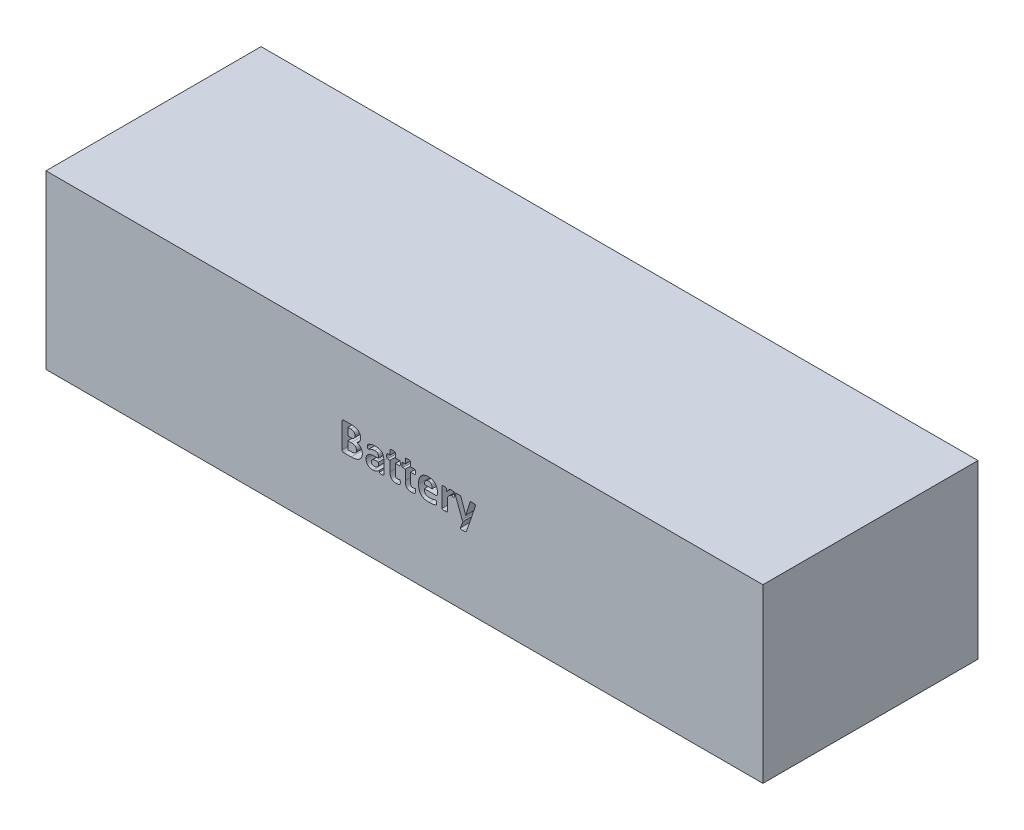
from build123d import *

# Parameters (mm, degrees)
SKETCH1_W           = 500
SKETCH1_H           = 120
BOSS_EXTRUDE1_DEPTH = 150
CUT_EXTRUDE1_DEPTH  = 10


with BuildPart() as part:
    # Sketch1 → Boss-Extrude1 (new body)
    with BuildSketch(Plane.XY):
        Rectangle(SKETCH1_W, SKETCH1_H)
    extrude(amount=BOSS_EXTRUDE1_DEPTH)

    # Sketch2 → Cut-Extrude1 (cut)
    with BuildSketch(Plane.XY.offset(150)):
        with BuildLine():
            add(Edge.make_bspline(
                [(-29.389203198, -0.522577242), (-29.392504078, -0.69222212), (-29.398977209, -1.024901137), (-29.454384378, -1.512436541), (-29.542909639, -1.976332964), (-29.668986073, -2.41438336), (-29.829526734, -2.824338476), (-30.007530188, -3.215106909), (-30.219628532, -3.578967128), (-30.45954757, -3.918915264), (-30.726422991, -4.233111364), (-31.013436073, -4.528778521), (-31.332578049, -4.792760853), (-31.78396216, -5.126625411), (-32.409994719, -5.482220629), (-33.220744095, -5.8292766), (-34.097537507, -6.088226347), (-34.867437693, -6.240005424), (-35.516882295, -6.322710703), (-36.03629251, -6.367237394), (-36.582653361, -6.394401234), (-36.956401093, -6.397690597), (-37.14692621, -6.399367413)],
                knots=[0, 0, 0, 0, 0.924869681, 1.813698953, 2.671929785, 3.497741784, 4.295238828, 5.071047982, 5.837050105, 6.588235223, 7.337056364, 8.083192266, 8.832013407, 9.592756872, 11.143016317, 12.74439455, 14.392794953, 16.118857481, 17.017754023, 17.961953565, 18.961066516, 20, 20, 20, 20], degree=3))
            Line((-37.14692621, -6.399367413), (-42.326241283, -6.399367413))
            add(Edge.make_bspline(
                [(-42.326241283, -6.399367413), (-42.406047684, -6.396172219), (-42.560144742, -6.390002664), (-42.783672631, -6.33429987), (-42.984788028, -6.238257068), (-43.171002952, -6.11287696), (-43.325125901, -5.93741184), (-43.425182233, -5.709751978), (-43.489795596, -5.441447853), (-43.496890124, -5.247856286), (-43.50069935, -5.143912238)],
                knots=[0, 0, 0, 0, 0.978793994, 1.889939582, 2.804428835, 3.703585142, 4.63041425, 5.627232269, 6.726002966, 8, 8, 8, 8], degree=3))
            Line((-43.50069935, -5.143912238), (-43.50069935, 11.928478195))
            add(Edge.make_bspline(
                [(-43.50069935, 11.928478195), (-43.496811216, 12.032392918), (-43.489569724, 12.225929869), (-43.426228101, 12.493263141), (-43.32397279, 12.718626901), (-43.169706837, 12.892493891), (-42.986302589, 13.023492234), (-42.783479905, 13.118588137), (-42.560197039, 13.174643972), (-42.406065527, 13.180763884), (-42.326241283, 13.183933369)],
                knots=[0, 0, 0, 0, 1.274945825, 2.374534816, 3.355443708, 4.282963059, 5.193482606, 6.108652912, 7.020477063, 8, 8, 8, 8], degree=3))
            Line((-42.326241283, 13.183933369), (-37.425916249, 13.183933369))
            add(Edge.make_bspline(
                [(-37.425916249, 13.183933369), (-37.139318902, 13.18112109), (-36.586474342, 13.175696221), (-35.793268987, 13.116732227), (-35.067486787, 13.023092055), (-34.406097693, 12.895564456), (-33.803680828, 12.722043568), (-33.249439583, 12.518450127), (-32.748952555, 12.264274438), (-32.295844863, 11.975969666), (-31.889192629, 11.65043714), (-31.537767337, 11.280191934), (-31.236717403, 10.868216764), (-30.983314365, 10.417534962), (-30.786292431, 9.923861306), (-30.640030909, 9.390107338), (-30.554988811, 8.81433785), (-30.545848203, 8.415886058), (-30.541162068, 8.211610905)],
                knots=[0, 0, 0, 0, 1.422535359, 2.744062161, 3.945671556, 5.054054835, 6.084028266, 7.054893494, 7.980650676, 8.864712083, 9.717130842, 10.559835018, 11.390878574, 12.24430494, 13.119573574, 14.022776017, 14.986332244, 16, 16, 16, 16], degree=3))
            add(Edge.make_bspline(
                [(-30.541162068, 8.211610905), (-30.549470182, 7.981431788), (-30.565801637, 7.52896333), (-30.703858776, 6.875425266), (-30.924208584, 6.269213116), (-31.231935264, 5.7198456), (-31.625496819, 5.231303791), (-32.097301907, 4.808347194), (-32.640393257, 4.444409803), (-33.047160307, 4.275088914), (-33.254565186, 4.18875454)],
                knots=[0, 0, 0, 0, 1.064274459, 2.092069132, 3.075913786, 4.039345789, 4.992217936, 5.965278652, 6.962523792, 8, 8, 8, 8], degree=3))
            add(Edge.make_bspline(
                [(-33.254565186, 4.18875454), (-33.119121116, 4.160665196), (-32.850280107, 4.104911055), (-32.458115034, 3.988357529), (-32.084227882, 3.838625604), (-31.727223164, 3.663195415), (-31.389176093, 3.459285828), (-31.067457985, 3.232366103), (-30.776521906, 2.96813342), (-30.504292974, 2.68369598), (-30.255058051, 2.374342169), (-30.040297334, 2.032121108), (-29.844362606, 1.668742066), (-29.684190854, 1.276007438), (-29.552100894, 0.861189762), (-29.458617994, 0.421193283), (-29.397791611, -0.042387568), (-29.39210409, -0.360384494), (-29.389203198, -0.522577242)],
                knots=[0, 0, 0, 0, 0.996598969, 1.978135123, 2.943647814, 3.896000454, 4.841457252, 5.786419563, 6.728099347, 7.668537465, 8.622361299, 9.584904388, 10.576213204, 11.593984834, 12.63670833, 13.709533826, 14.831759139, 16, 16, 16, 16], degree=3))
        make_face()
        with BuildLine():
            add(Edge.make_bspline(
                [(-34.573018111, 7.775126489), (-34.581179947, 7.964982884), (-34.596875041, 8.330074043), (-34.729526291, 8.845202786), (-34.941811852, 9.296146249), (-35.257488186, 9.664917646), (-35.659013468, 9.955212287), (-36.064378704, 10.116546405), (-36.435339134, 10.21869895), (-36.76747533, 10.268862997), (-37.143280217, 10.300801742), (-37.407836416, 10.302919108), (-37.547411911, 10.304036195)],
                knots=[0, 0, 0, 0, 1.269297621, 2.440841347, 3.536685647, 4.57691547, 5.655600639, 6.821276254, 7.476564334, 8.229395514, 9.06585823, 10, 10, 10, 10], degree=3))
            Line((-37.547411911, 10.304036195), (-39.468843306, 10.304036195))
            Line((-39.468843306, 10.304036195), (-39.468843306, 5.120221282))
            Line((-39.468843306, 5.120221282), (-37.344919141, 5.120221282))
            add(Edge.make_bspline(
                [(-37.344919141, 5.120221282), (-37.214280366, 5.122402547), (-36.96581011, 5.126551233), (-36.61536102, 5.168152582), (-36.305069192, 5.227860039), (-35.955043078, 5.346946433), (-35.577163407, 5.554458468), (-35.203042448, 5.886141458), (-34.915476582, 6.288602931), (-34.720869548, 6.750801071), (-34.595251161, 7.251042352), (-34.580495162, 7.598875197), (-34.573018111, 7.775126489)],
                knots=[0, 0, 0, 0, 0.897651758, 1.707301395, 2.423204266, 3.065599642, 4.242445143, 5.359969752, 6.47597094, 7.611991682, 8.789966051, 10, 10, 10, 10], degree=3))
        make_face(mode=Mode.SUBTRACT)
        with BuildLine():
            add(Edge.make_bspline(
                [(-33.421059242, -0.585574993), (-33.423520691, -0.47595297), (-33.428293041, -0.263413656), (-33.469171059, 0.047471883), (-33.540211263, 0.338779236), (-33.641442708, 0.61045153), (-33.761632842, 0.86655433), (-33.914483296, 1.098549624), (-34.093379626, 1.309500689), (-34.297744797, 1.499065016), (-34.528437383, 1.67222786), (-34.791894443, 1.820935363), (-35.086046489, 1.944535604), (-35.409810461, 2.05544354), (-35.774183292, 2.14129615), (-36.187044737, 2.196720279), (-36.649813125, 2.232632812), (-36.975856904, 2.237677337), (-37.14692621, 2.240324109)],
                knots=[0, 0, 0, 0, 0.985477707, 1.910681348, 2.813592447, 3.675578793, 4.514135175, 5.352148978, 6.165595806, 6.995866717, 7.853727436, 8.753813147, 9.708438657, 10.71934223, 11.82842252, 13.068320276, 14.461800387, 16, 16, 16, 16], degree=3))
            Line((-37.14692621, 2.240324109), (-39.468843306, 2.240324109))
            Line((-39.468843306, 2.240324109), (-39.468843306, -3.231480521))
            Line((-39.468843306, -3.231480521), (-36.638444365, -3.231480521))
            add(Edge.make_bspline(
                [(-36.638444365, -3.231480521), (-36.50780833, -3.230892295), (-36.254986153, -3.22975389), (-35.89509041, -3.189305571), (-35.564112034, -3.144832414), (-35.177460383, -3.042713013), (-34.740365421, -2.869917994), (-34.283288866, -2.573889565), (-33.911939435, -2.189303071), (-33.683360751, -1.804488761), (-33.543508017, -1.466116428), (-33.475411932, -1.186735923), (-33.426820652, -0.891755453), (-33.423010798, -0.689287196), (-33.421059242, -0.585574993)],
                knots=[0, 0, 0, 0, 0.996438702, 1.928425049, 2.762412092, 3.542798089, 4.97591562, 6.331990048, 7.668146545, 9.019184108, 9.722981391, 10.456157892, 11.209183361, 12, 12, 12, 12], degree=3))
        make_face(mode=Mode.SUBTRACT)
        with BuildLine():
            add(Edge.make_bspline(
                [(-14.413737895, -5.836887496), (-14.418770545, -5.903865725), (-14.428547402, -6.03398338), (-14.56760196, -6.194017502), (-14.781802833, -6.288821213), (-15.006436653, -6.344232638), (-15.236856633, -6.370041042), (-15.457340555, -6.389052052), (-15.718661831, -6.395735991), (-15.906188983, -6.398100383), (-16.006681019, -6.399367413)],
                knots=[0, 0, 0, 0, 0.847661055, 1.646739115, 2.582838834, 3.842570661, 4.623823176, 5.576626076, 6.701362571, 8, 8, 8, 8], degree=3))
            add(Edge.make_bspline(
                [(-16.006681019, -6.399367413), (-16.113187169, -6.398340274), (-16.309739574, -6.396444735), (-16.581283194, -6.387147356), (-16.806671031, -6.375890443), (-17.032775953, -6.349316641), (-17.246525952, -6.29520687), (-17.445003496, -6.194519781), (-17.554733936, -6.026933338), (-17.563473172, -5.902908679), (-17.568125268, -5.836887496)],
                knots=[0, 0, 0, 0, 1.386548692, 2.558814494, 3.536916243, 4.324071477, 5.517771642, 6.401890461, 7.149289469, 8, 8, 8, 8], degree=3))
            Line((-17.568125268, -5.836887496), (-17.568125268, -4.761425895))
            add(Edge.make_bspline(
                [(-17.568125268, -4.761425895), (-17.709508027, -4.905220661), (-17.990749847, -5.1912605), (-18.45626636, -5.568151099), (-18.950501933, -5.899091938), (-19.471161683, -6.183692242), (-20.023320189, -6.413322988), (-20.609594653, -6.566784106), (-21.222745647, -6.671638351), (-21.643025791, -6.682062865), (-21.856472153, -6.68735713)],
                knots=[0, 0, 0, 0, 0.999025191, 1.987283781, 2.962731982, 3.94425428, 4.924621166, 5.918486269, 6.942868133, 8, 8, 8, 8], degree=3))
            add(Edge.make_bspline(
                [(-21.856472153, -6.68735713), (-22.033633695, -6.684225737), (-22.379813894, -6.678106879), (-22.887700802, -6.620605626), (-23.374172675, -6.537745902), (-23.838193126, -6.416645406), (-24.274771125, -6.259466833), (-24.68254979, -6.06899663), (-25.062914388, -5.849379895), (-25.41132417, -5.592576634), (-25.722527155, -5.298213021), (-25.999122653, -4.9724424), (-26.237959903, -4.61418924), (-26.444258426, -4.225706825), (-26.59961138, -3.797975281), (-26.718007278, -3.338884113), (-26.785093097, -2.843465636), (-26.793144542, -2.502704143), (-26.797295742, -2.327012815)],
                knots=[0, 0, 0, 0, 1.140483104, 2.228546132, 3.287799885, 4.316350563, 5.312457115, 6.271822403, 7.211186946, 8.136591208, 9.052264771, 9.963802042, 10.88273062, 11.820305517, 12.789203481, 13.805984309, 14.868799623, 16, 16, 16, 16], degree=3))
            add(Edge.make_bspline(
                [(-26.797295742, -2.327012815), (-26.793389162, -2.137573054), (-26.785806592, -1.76987537), (-26.690435052, -1.238962243), (-26.549952653, -0.74452537), (-26.344464395, -0.288834229), (-26.082134384, 0.127361193), (-25.762572356, 0.505900321), (-25.38488162, 0.845198358), (-24.948955991, 1.147691782), (-24.455700737, 1.411626129), (-23.909287255, 1.641920038), (-23.305846568, 1.829153275), (-22.646981863, 1.981595167), (-21.932406143, 2.09488639), (-21.16379412, 2.181601705), (-20.340632962, 2.229368245), (-19.773104047, 2.236597571), (-19.480556985, 2.240324109)],
                knots=[0, 0, 0, 0, 0.930281648, 1.805652644, 2.643434735, 3.452148082, 4.254209686, 5.054947895, 5.879940667, 6.7433, 7.657362619, 8.625742791, 9.654340048, 10.759876155, 11.948048164, 13.209575455, 14.561605444, 16, 16, 16, 16], degree=3))
            Line((-19.480556985, 2.240324109), (-18.157604221, 2.240324109))
            Line((-18.157604221, 2.240324109), (-18.157604221, 3.086293903))
            add(Edge.make_bspline(
                [(-18.157604221, 3.086293903), (-18.162154941, 3.292360629), (-18.170687606, 3.678738674), (-18.271770599, 4.218110125), (-18.428437192, 4.685854355), (-18.693003987, 5.065027685), (-19.042142322, 5.368827088), (-19.413639618, 5.524781854), (-19.749414044, 5.612198808), (-20.037188151, 5.659782976), (-20.354250102, 5.693031033), (-20.575419184, 5.695112719), (-20.691013766, 5.696200717)],
                knots=[0, 0, 0, 0, 1.458536489, 2.734776677, 3.878437504, 4.92544373, 5.973744821, 7.115921979, 7.742601458, 8.433051669, 9.181030477, 10, 10, 10, 10], degree=3))
            add(Edge.make_bspline(
                [(-20.691013766, 5.696200717), (-20.84409417, 5.693685995), (-21.14181946, 5.688795124), (-21.576723433, 5.648613083), (-21.986061607, 5.577509095), (-22.48453643, 5.444747925), (-23.054277971, 5.253998012), (-23.663392776, 4.993128432), (-24.18526918, 4.738509187), (-24.555925896, 4.530334275), (-24.807230598, 4.380703958), (-24.974590564, 4.318120679), (-25.120086847, 4.26416613), (-25.214456515, 4.258764562), (-25.25835069, 4.25625213)],
                knots=[0, 0, 0, 0, 1.136757713, 2.210874221, 3.240152045, 4.21824245, 6.039499857, 7.696795992, 9.13659946, 10.348440785, 10.856985134, 11.301743508, 11.67521988, 12, 12, 12, 12], degree=3))
            add(Edge.make_bspline(
                [(-25.25835069, 4.25625213), (-25.311745075, 4.261727309), (-25.416262536, 4.27244476), (-25.562267477, 4.35183816), (-25.676796373, 4.483103803), (-25.774217773, 4.655861762), (-25.840012145, 4.872786165), (-25.895629953, 5.126804937), (-25.923920903, 5.418121577), (-25.930091294, 5.624165339), (-25.93332659, 5.732199432)],
                knots=[0, 0, 0, 0, 0.718163752, 1.405777981, 2.178533946, 3.038943502, 4.062203321, 5.22045479, 6.542612302, 8, 8, 8, 8], degree=3))
            add(Edge.make_bspline(
                [(-25.93332659, 5.732199432), (-25.9302698, 5.867200384), (-25.92483664, 6.107152032), (-25.878747642, 6.438928432), (-25.756804926, 6.708297076), (-25.605281193, 6.901775742), (-25.439583809, 7.047386715), (-25.27229105, 7.16675618), (-25.067324383, 7.29765099), (-24.733127488, 7.495715091), (-24.247137818, 7.746099159), (-23.584916933, 8.004353872), (-22.853047909, 8.246365497), (-22.053237434, 8.426093468), (-21.209511289, 8.554076761), (-20.631500448, 8.568715831), (-20.340026298, 8.576097891)],
                knots=[0, 0, 0, 0, 0.826658441, 1.469308558, 2.032047218, 2.613912067, 2.958349689, 3.378648177, 3.869887561, 4.445861981, 5.754983526, 7.20845133, 8.789953761, 10.466056555, 12.217934526, 14, 14, 14, 14], degree=3))
            add(Edge.make_bspline(
                [(-20.340026298, 8.576097891), (-20.086429253, 8.573157505), (-19.596501987, 8.567476938), (-18.891243026, 8.509848293), (-18.243553505, 8.410330467), (-17.650879148, 8.27839517), (-17.111581095, 8.101906877), (-16.621192433, 7.88887784), (-16.185490034, 7.623188236), (-15.793678283, 7.321979687), (-15.453124547, 6.971756269), (-15.162880789, 6.576377212), (-14.922039265, 6.134632764), (-14.734453271, 5.644933184), (-14.594014958, 5.109964852), (-14.48213847, 4.531823088), (-14.428735647, 3.904762), (-14.418845373, 3.471850032), (-14.413737895, 3.248288119)],
                knots=[0, 0, 0, 0, 1.317245853, 2.544803546, 3.672193757, 4.719393239, 5.695189719, 6.61611763, 7.490092295, 8.339581991, 9.177158916, 10.01874955, 10.880057752, 11.783008764, 12.735695387, 13.750474329, 14.838312871, 16, 16, 16, 16], degree=3))
            Line((-14.413737895, 3.248288119), (-14.413737895, -5.836887496))
        make_face()
        with BuildLine():
            Line((-18.157604221, -0.06359363), (-19.615552165, -0.06359363))
            add(Edge.make_bspline(
                [(-19.615552165, -0.06359363), (-19.764092615, -0.065195719), (-20.050935682, -0.068289476), (-20.46393887, -0.09530735), (-20.844260594, -0.13907202), (-21.189382908, -0.202806544), (-21.505471758, -0.276530741), (-21.786864777, -0.377491804), (-22.043547446, -0.486759788), (-22.328725961, -0.664684758), (-22.631579585, -0.918346516), (-22.882733058, -1.302678742), (-23.026669579, -1.744099568), (-23.044239162, -2.055913708), (-23.053429416, -2.219016671)],
                knots=[0, 0, 0, 0, 1.163507281, 2.246822312, 3.240808781, 4.16040749, 4.99541618, 5.779516542, 6.500121047, 7.175220986, 8.407704522, 9.56138043, 10.724412955, 12, 12, 12, 12], degree=3))
            add(Edge.make_bspline(
                [(-23.053429416, -2.219016671), (-23.04624314, -2.357543623), (-23.032450117, -2.623426181), (-22.935026382, -3.001559508), (-22.758000324, -3.328093914), (-22.520986986, -3.608231385), (-22.221026606, -3.830862955), (-21.863110849, -3.98355665), (-21.45656824, -4.080303297), (-21.167097515, -4.090232576), (-21.015002198, -4.095449674)],
                knots=[0, 0, 0, 0, 1.059950426, 2.034422386, 2.958730888, 3.878753548, 4.822247058, 5.788368866, 6.837952474, 8, 8, 8, 8], degree=3))
            add(Edge.make_bspline(
                [(-21.015002198, -4.095449674), (-20.882539157, -4.090541037), (-20.621063227, -4.080851616), (-20.239935236, -3.995232166), (-19.873933201, -3.864995449), (-19.524813516, -3.674268842), (-19.178766094, -3.438425824), (-18.841348042, -3.1455975), (-18.488836837, -2.81884416), (-18.270841196, -2.569190438), (-18.157604221, -2.439508799)],
                knots=[0, 0, 0, 0, 0.93008171, 1.83593838, 2.733223734, 3.653087759, 4.624110121, 5.671802727, 6.790627123, 8, 8, 8, 8], degree=3))
            Line((-18.157604221, -2.439508799), (-18.157604221, -0.06359363))
        make_face(mode=Mode.SUBTRACT)
        with BuildLine():
            add(Edge.make_bspline(
                [(-2.8941492, -4.554433286), (-2.895071012, -4.657930112), (-2.896808658, -4.853025098), (-2.907888476, -5.126619151), (-2.935429002, -5.362358943), (-2.978483082, -5.608420083), (-3.049807973, -5.846614206), (-3.173901045, -6.072890111), (-3.369467517, -6.20994666), (-3.595678708, -6.329801314), (-3.879522496, -6.428935238), (-4.201358129, -6.523998662), (-4.564825688, -6.593420867), (-4.953767014, -6.646907341), (-5.361102091, -6.67739029), (-5.636008346, -6.684025438), (-5.774046374, -6.68735713)],
                knots=[0, 0, 0, 0, 1.018499383, 1.919905479, 2.692481734, 3.352538174, 4.374773615, 5.136702927, 5.830547525, 6.682250554, 7.658264028, 8.779388885, 9.983517096, 11.294356614, 12.641421686, 14, 14, 14, 14], degree=3))
            add(Edge.make_bspline(
                [(-5.774046374, -6.68735713), (-5.9526829, -6.684073348), (-6.300314747, -6.677683014), (-6.803005087, -6.623569431), (-7.270252396, -6.534840008), (-7.699488248, -6.408054151), (-8.096599009, -6.250446374), (-8.447815933, -6.034947911), (-8.778741269, -5.801797643), (-9.060378955, -5.510854035), (-9.317503342, -5.19226489), (-9.526236362, -4.8264872), (-9.708862683, -4.42849571), (-9.852211322, -3.988951762), (-9.957064503, -3.507523196), (-10.039842352, -2.986451574), (-10.081713237, -2.422183557), (-10.08974316, -2.033077424), (-10.093892134, -1.832030489)],
                knots=[0, 0, 0, 0, 1.143209156, 2.224718086, 3.232130876, 4.183055058, 5.08706435, 5.95650602, 6.814903494, 7.670342544, 8.538564019, 9.429424879, 10.35753592, 11.33824033, 12.381747034, 13.508835832, 14.712842388, 16, 16, 16, 16], degree=3))
            Line((-10.093892134, -1.832030489), (-10.093892134, 5.120221282))
            Line((-10.093892134, 5.120221282), (-11.781331885, 5.120221282))
            add(Edge.make_bspline(
                [(-11.781331885, 5.120221282), (-11.828553865, 5.124610273), (-11.923545413, 5.133439148), (-12.057128052, 5.205636046), (-12.158674337, 5.331944887), (-12.253450455, 5.493673653), (-12.316666046, 5.714044073), (-12.363921064, 5.989902337), (-12.394944728, 6.327029863), (-12.396806585, 6.572103414), (-12.397809873, 6.704164728)],
                knots=[0, 0, 0, 0, 0.608454084, 1.223963833, 1.896604122, 2.677721025, 3.63370286, 4.834772068, 6.29437262, 8, 8, 8, 8], degree=3))
            add(Edge.make_bspline(
                [(-12.397809873, 6.704164728), (-12.396907474, 6.842247468), (-12.395246869, 7.096348622), (-12.36373655, 7.443714661), (-12.31831497, 7.723468205), (-12.252405091, 7.940859468), (-12.162316898, 8.101206749), (-12.049078484, 8.210712855), (-11.916051326, 8.281463108), (-11.818217126, 8.285849285), (-11.767832367, 8.288108173)],
                knots=[0, 0, 0, 0, 1.761495135, 3.241519888, 4.446868353, 5.37304053, 6.12812549, 6.764440492, 7.363684998, 8, 8, 8, 8], degree=3))
            Line((-11.767832367, 8.288108173), (-10.093892134, 8.288108173))
            Line((-10.093892134, 8.288108173), (-10.093892134, 11.379497796))
            add(Edge.make_bspline(
                [(-10.093892134, 11.379497796), (-10.089053732, 11.429506118), (-10.079608309, 11.527131259), (-10.017235082, 11.670725447), (-9.890574573, 11.790736865), (-9.698814744, 11.885096473), (-9.43881813, 11.951914709), (-9.105316764, 11.998092178), (-8.695018617, 12.029409525), (-8.394522007, 12.031070444), (-8.23095865, 12.031974499)],
                knots=[0, 0, 0, 0, 0.555792782, 1.085006378, 1.697298473, 2.449599768, 3.435457661, 4.664787881, 6.184610163, 8, 8, 8, 8], degree=3))
            add(Edge.make_bspline(
                [(-8.23095865, 12.031974499), (-8.061381196, 12.031223604), (-7.75485938, 12.029866315), (-7.340161953, 11.998121185), (-7.010678538, 11.952988147), (-6.75613565, 11.883547831), (-6.565820616, 11.789772773), (-6.437776232, 11.669849541), (-6.362175423, 11.529468823), (-6.354105299, 11.429853742), (-6.350025809, 11.379497796)],
                knots=[0, 0, 0, 0, 1.871583765, 3.383004285, 4.589165911, 5.537728361, 6.285870842, 6.906598326, 7.447279709, 8, 8, 8, 8], degree=3))
            Line((-6.350025809, 11.379497796), (-6.350025809, 8.288108173))
            Line((-6.350025809, 8.288108173), (-3.483628153, 8.288108173))
            add(Edge.make_bspline(
                [(-3.483628153, 8.288108173), (-3.436098765, 8.285924273), (-3.343666603, 8.281677161), (-3.219732041, 8.208695188), (-3.110715346, 8.101967527), (-3.033163399, 7.937864839), (-2.962651066, 7.724494958), (-2.924904459, 7.443127797), (-2.897796375, 7.096250886), (-2.895433736, 6.842257499), (-2.8941492, 6.704164728)],
                knots=[0, 0, 0, 0, 0.606601294, 1.179680027, 1.810926383, 2.557524531, 3.496505428, 4.715283139, 6.214143845, 8, 8, 8, 8], degree=3))
            add(Edge.make_bspline(
                [(-2.8941492, 6.704164728), (-2.895839013, 6.572161108), (-2.898973236, 6.327324103), (-2.921951432, 5.989651404), (-2.971855077, 5.714533345), (-3.030933247, 5.495824494), (-3.114628119, 5.331083043), (-3.21175137, 5.207911395), (-3.336172811, 5.133338984), (-3.425772515, 5.124564881), (-3.470128635, 5.120221282)],
                knots=[0, 0, 0, 0, 1.729548919, 3.207923959, 4.425838243, 5.389435566, 6.162763598, 6.831980712, 7.421774833, 8, 8, 8, 8], degree=3))
            Line((-3.470128635, 5.120221282), (-6.350025809, 5.120221282))
            Line((-6.350025809, 5.120221282), (-6.350025809, -1.287549929))
            add(Edge.make_bspline(
                [(-6.350025809, -1.287549929), (-6.345922323, -1.461753852), (-6.338215161, -1.788943496), (-6.276940538, -2.245128655), (-6.176361652, -2.634622408), (-6.030774747, -2.959575482), (-5.819669586, -3.220253043), (-5.534398088, -3.396651307), (-5.185774487, -3.502575496), (-4.933425241, -3.513558107), (-4.797581238, -3.519470239)],
                knots=[0, 0, 0, 0, 1.338302624, 2.513598729, 3.528575665, 4.42058712, 5.230802909, 6.065332582, 6.958534775, 8, 8, 8, 8], degree=3))
            add(Edge.make_bspline(
                [(-4.797581238, -3.519470239), (-4.704483438, -3.516764036), (-4.528027333, -3.511634741), (-4.275655225, -3.47643385), (-4.053811928, -3.414458587), (-3.854447202, -3.354531743), (-3.68802122, -3.284122304), (-3.544436402, -3.23005936), (-3.423627861, -3.18210473), (-3.344490876, -3.175854184), (-3.308134419, -3.17298261)],
                knots=[0, 0, 0, 0, 1.451015613, 2.750232136, 3.957898215, 5.037257872, 5.992252106, 6.769310614, 7.434606887, 8, 8, 8, 8], degree=3))
            add(Edge.make_bspline(
                [(-3.308134419, -3.17298261), (-3.277658316, -3.175536516), (-3.216855503, -3.180631808), (-3.129867579, -3.225356741), (-3.049752039, -3.310172413), (-3.005382033, -3.453077689), (-2.958624626, -3.640130334), (-2.926075752, -3.88630795), (-2.896870382, -4.196744915), (-2.89512005, -4.42681897), (-2.8941492, -4.554433286)],
                knots=[0, 0, 0, 0, 0.4674882, 0.932684777, 1.472328649, 2.219223126, 3.194753865, 4.456631174, 6.034612855, 8, 8, 8, 8], degree=3))
        make_face()
        with BuildLine():
            add(Edge.make_bspline(
                [(7.761470343, -4.554433286), (7.760548531, -4.657930112), (7.758810885, -4.853025098), (7.747731067, -5.126619151), (7.720190541, -5.362358943), (7.677136461, -5.608420083), (7.60581157, -5.846614206), (7.481718498, -6.072890111), (7.286152026, -6.20994666), (7.059940835, -6.329801314), (6.776097047, -6.428935238), (6.454261413, -6.523998662), (6.090793854, -6.593420867), (5.701852529, -6.646907341), (5.294517452, -6.67739029), (5.019611196, -6.684025438), (4.881573169, -6.68735713)],
                knots=[0, 0, 0, 0, 1.018499383, 1.919905479, 2.692481734, 3.352538174, 4.374773615, 5.136702927, 5.830547525, 6.682250554, 7.658264028, 8.779388885, 9.983517096, 11.294356614, 12.641421686, 14, 14, 14, 14], degree=3))
            add(Edge.make_bspline(
                [(4.881573169, -6.68735713), (4.702936643, -6.684073348), (4.355304796, -6.677683014), (3.852614456, -6.623569431), (3.385367147, -6.534840008), (2.956131294, -6.408054151), (2.559020534, -6.250446374), (2.207803609, -6.034947911), (1.876878274, -5.801797643), (1.595240588, -5.510854035), (1.338116201, -5.19226489), (1.12938318, -4.8264872), (0.94675686, -4.42849571), (0.80340822, -3.988951762), (0.69855504, -3.507523196), (0.615777191, -2.986451574), (0.573906306, -2.422183557), (0.565876383, -2.033077424), (0.561727408, -1.832030489)],
                knots=[0, 0, 0, 0, 1.143209156, 2.224718086, 3.232130876, 4.183055058, 5.08706435, 5.95650602, 6.814903494, 7.670342544, 8.538564019, 9.429424879, 10.35753592, 11.33824033, 12.381747034, 13.508835832, 14.712842388, 16, 16, 16, 16], degree=3))
            Line((0.561727408, -1.832030489), (0.561727408, 5.120221282))
            Line((0.561727408, 5.120221282), (-1.125712342, 5.120221282))
            add(Edge.make_bspline(
                [(-1.125712342, 5.120221282), (-1.172934322, 5.124610273), (-1.267925871, 5.133439148), (-1.401508509, 5.205636046), (-1.503054795, 5.331944887), (-1.597830912, 5.493673653), (-1.661046503, 5.714044073), (-1.708301521, 5.989902337), (-1.739325185, 6.327029863), (-1.741187043, 6.572103414), (-1.742190331, 6.704164728)],
                knots=[0, 0, 0, 0, 0.608454084, 1.223963833, 1.896604122, 2.677721025, 3.63370286, 4.834772068, 6.29437262, 8, 8, 8, 8], degree=3))
            add(Edge.make_bspline(
                [(-1.742190331, 6.704164728), (-1.741287931, 6.842247468), (-1.739627326, 7.096348622), (-1.708117007, 7.443714661), (-1.662695428, 7.723468205), (-1.596785548, 7.940859468), (-1.506697355, 8.101206749), (-1.393458941, 8.210712855), (-1.260431783, 8.281463108), (-1.162597584, 8.285849285), (-1.112212824, 8.288108173)],
                knots=[0, 0, 0, 0, 1.761495135, 3.241519888, 4.446868353, 5.37304053, 6.12812549, 6.764440492, 7.363684998, 8, 8, 8, 8], degree=3))
            Line((-1.112212824, 8.288108173), (0.561727408, 8.288108173))
            Line((0.561727408, 8.288108173), (0.561727408, 11.379497796))
            add(Edge.make_bspline(
                [(0.561727408, 11.379497796), (0.566565811, 11.429506118), (0.576011234, 11.527131259), (0.638384461, 11.670725447), (0.76504497, 11.790736865), (0.956804799, 11.885096473), (1.216801413, 11.951914709), (1.550302778, 11.998092178), (1.960600926, 12.029409525), (2.261097535, 12.031070444), (2.424660893, 12.031974499)],
                knots=[0, 0, 0, 0, 0.555792782, 1.085006378, 1.697298473, 2.449599768, 3.435457661, 4.664787881, 6.184610163, 8, 8, 8, 8], degree=3))
            add(Edge.make_bspline(
                [(2.424660893, 12.031974499), (2.594238347, 12.031223604), (2.900760163, 12.029866315), (3.31545759, 11.998121185), (3.644941005, 11.952988147), (3.899483893, 11.883547831), (4.089798926, 11.789772773), (4.217843311, 11.669849541), (4.29344412, 11.529468823), (4.301514244, 11.429853742), (4.305593734, 11.379497796)],
                knots=[0, 0, 0, 0, 1.871583765, 3.383004285, 4.589165911, 5.537728361, 6.285870842, 6.906598326, 7.447279709, 8, 8, 8, 8], degree=3))
            Line((4.305593734, 11.379497796), (4.305593734, 8.288108173))
            Line((4.305593734, 8.288108173), (7.17199139, 8.288108173))
            add(Edge.make_bspline(
                [(7.17199139, 8.288108173), (7.219520777, 8.285924273), (7.311952939, 8.281677161), (7.435887502, 8.208695188), (7.544904196, 8.101967527), (7.622456143, 7.937864839), (7.692968477, 7.724494958), (7.730715084, 7.443127797), (7.757823167, 7.096250886), (7.760185807, 6.842257499), (7.761470343, 6.704164728)],
                knots=[0, 0, 0, 0, 0.606601294, 1.179680027, 1.810926383, 2.557524531, 3.496505428, 4.715283139, 6.214143845, 8, 8, 8, 8], degree=3))
            add(Edge.make_bspline(
                [(7.761470343, 6.704164728), (7.759780529, 6.572161108), (7.756646306, 6.327324103), (7.733668111, 5.989651404), (7.683764466, 5.714533345), (7.624686296, 5.495824494), (7.540991423, 5.331083043), (7.443868172, 5.207911395), (7.319446731, 5.133338984), (7.229847028, 5.124564881), (7.185490908, 5.120221282)],
                knots=[0, 0, 0, 0, 1.729548919, 3.207923959, 4.425838243, 5.389435566, 6.162763598, 6.831980712, 7.421774833, 8, 8, 8, 8], degree=3))
            Line((7.185490908, 5.120221282), (4.305593734, 5.120221282))
            Line((4.305593734, 5.120221282), (4.305593734, -1.287549929))
            add(Edge.make_bspline(
                [(4.305593734, -1.287549929), (4.309697219, -1.461753852), (4.317404381, -1.788943496), (4.378679005, -2.245128655), (4.479257891, -2.634622408), (4.624844796, -2.959575482), (4.835949957, -3.220253043), (5.121221455, -3.396651307), (5.469845055, -3.502575496), (5.722194302, -3.513558107), (5.858038304, -3.519470239)],
                knots=[0, 0, 0, 0, 1.338302624, 2.513598729, 3.528575665, 4.42058712, 5.230802909, 6.065332582, 6.958534775, 8, 8, 8, 8], degree=3))
            add(Edge.make_bspline(
                [(5.858038304, -3.519470239), (5.951136105, -3.516764036), (6.127592209, -3.511634741), (6.379964318, -3.47643385), (6.601807615, -3.414458587), (6.801172341, -3.354531743), (6.967598323, -3.284122304), (7.111183141, -3.23005936), (7.231991682, -3.18210473), (7.311128667, -3.175854184), (7.347485124, -3.17298261)],
                knots=[0, 0, 0, 0, 1.451015613, 2.750232136, 3.957898215, 5.037257872, 5.992252106, 6.769310614, 7.434606887, 8, 8, 8, 8], degree=3))
            add(Edge.make_bspline(
                [(7.347485124, -3.17298261), (7.377961227, -3.175536516), (7.43876404, -3.180631808), (7.525751964, -3.225356741), (7.605867503, -3.310172413), (7.65023751, -3.453077689), (7.696994916, -3.640130334), (7.729543791, -3.88630795), (7.758749161, -4.196744915), (7.760499492, -4.42681897), (7.761470343, -4.554433286)],
                knots=[0, 0, 0, 0, 0.4674882, 0.932684777, 1.472328649, 2.219223126, 3.194753865, 4.456631174, 6.034612855, 8, 8, 8, 8], degree=3))
        make_face()
        with BuildLine():
            add(Edge.make_bspline(
                [(23.024925363, 1.308857366), (23.022375875, 1.199051201), (23.017583154, 0.992629245), (22.959329427, 0.706606725), (22.86496033, 0.463528266), (22.729921473, 0.266519098), (22.557036964, 0.118905532), (22.357757531, 0.012372744), (22.128715244, -0.050983951), (21.96636745, -0.059280451), (21.881966172, -0.06359363)],
                knots=[0, 0, 0, 0, 1.294612765, 2.433711247, 3.426773227, 4.355212281, 5.221450576, 6.08496969, 7.004415153, 8, 8, 8, 8], degree=3))
            Line((21.881966172, -0.06359363), (13.809254407, -0.06359363))
            add(Edge.make_bspline(
                [(13.809254407, -0.06359363), (13.817719817, -0.335810889), (13.834049936, -0.860929056), (13.964126727, -1.495253193), (14.120183005, -1.9546293), (14.26774043, -2.266292477), (14.440228895, -2.554443968), (14.650616409, -2.81342571), (14.889268369, -3.043262524), (15.159445702, -3.245177508), (15.461946968, -3.413491284), (15.793586405, -3.560883358), (16.161010869, -3.67158804), (16.56301678, -3.753270369), (17.000258281, -3.79531182), (17.302555075, -3.803323636), (17.458624107, -3.807459956)],
                knots=[0, 0, 0, 0, 1.903663833, 3.672244989, 4.50557282, 5.294539188, 6.08133739, 6.850283687, 7.622448094, 8.395111892, 9.203739045, 10.040498396, 10.930426153, 11.883675413, 12.907389242, 14, 14, 14, 14], degree=3))
            add(Edge.make_bspline(
                [(17.458624107, -3.807459956), (17.617671666, -3.805963725), (17.927007181, -3.803053668), (18.375633494, -3.774029025), (18.794980679, -3.736486078), (19.297255438, -3.658559541), (19.857362063, -3.539866924), (20.455511386, -3.38995974), (20.952434191, -3.228912192), (21.360760492, -3.090503795), (21.684613289, -2.967139641), (21.885743023, -2.950586693), (21.971962959, -2.943490804)],
                knots=[0, 0, 0, 0, 1.032587825, 2.008305496, 2.918325557, 3.76545214, 5.306936209, 6.634534545, 7.768107249, 8.695218624, 9.440668639, 10, 10, 10, 10], degree=3))
            add(Edge.make_bspline(
                [(21.971962959, -2.943490804), (22.012792121, -2.945699438), (22.089345811, -2.949840572), (22.19792896, -2.991904872), (22.283244612, -3.076933045), (22.350829559, -3.201312884), (22.4057176, -3.374623374), (22.429543701, -3.604431285), (22.448703802, -3.892587686), (22.44885974, -4.104382886), (22.448945928, -4.221445175)],
                knots=[0, 0, 0, 0, 0.64447298, 1.208371244, 1.795734494, 2.507831121, 3.430606498, 4.651842138, 6.14942443, 8, 8, 8, 8], degree=3))
            add(Edge.make_bspline(
                [(22.448945928, -4.221445175), (22.448382455, -4.324972728), (22.447336599, -4.517128897), (22.432495692, -4.782594523), (22.416520307, -5.008169322), (22.389190739, -5.197413451), (22.35686781, -5.359375055), (22.30032613, -5.493487602), (22.229214548, -5.61159083), (22.15276358, -5.707141207), (22.058481157, -5.783784026), (21.941127834, -5.844506713), (21.785355587, -5.915971203), (21.501141559, -6.023101273), (21.062506819, -6.165129215), (20.441345198, -6.317934244), (19.709892609, -6.459359592), (18.885181933, -6.585610918), (17.979488182, -6.674822687), (17.350853418, -6.683092192), (17.026639531, -6.68735713)],
                knots=[0, 0, 0, 0, 0.820157569, 1.522283989, 2.10659077, 2.610832581, 3.037538887, 3.410549094, 3.757056136, 4.128358326, 4.373375804, 4.713920547, 5.171303665, 5.731922403, 7.118816566, 8.822411122, 10.796660737, 13.020443986, 15.431829577, 18, 18, 18, 18], degree=3))
            add(Edge.make_bspline(
                [(17.026639531, -6.68735713), (16.733935746, -6.682843195), (16.166687053, -6.674095362), (15.343420182, -6.587679427), (14.576119375, -6.443950708), (13.861975425, -6.248886302), (13.205291965, -5.991954413), (12.603960683, -5.676052637), (12.062866251, -5.29446545), (11.570453878, -4.861118347), (11.140406283, -4.36305449), (10.776369158, -3.80095139), (10.456663662, -3.187341103), (10.207002088, -2.505970793), (10.015567323, -1.765370748), (9.878219247, -0.966170073), (9.790232851, -0.107557482), (9.781770359, 0.485159304), (9.777398364, 0.791375843)],
                knots=[0, 0, 0, 0, 1.172943548, 2.273119544, 3.313151866, 4.299234143, 5.235949601, 6.134252953, 7.014919285, 7.883684174, 8.757531119, 9.64298672, 10.562605475, 11.525241576, 12.544579471, 13.624945789, 14.772970672, 16, 16, 16, 16], degree=3))
            add(Edge.make_bspline(
                [(9.777398364, 0.791375843), (9.784051626, 1.085540246), (9.79704751, 1.660134556), (9.880723526, 2.500370657), (10.031198026, 3.294026694), (10.230592267, 4.043691157), (10.491924326, 4.742681583), (10.806481836, 5.38805798), (11.173146664, 5.978579756), (11.591988775, 6.513776574), (12.069319846, 6.985524477), (12.585461378, 7.410302664), (13.161404938, 7.760333255), (13.777972224, 8.059403562), (14.440732422, 8.292606584), (15.144902228, 8.459355594), (15.888260119, 8.559763662), (16.397846627, 8.5705822), (16.657652706, 8.576097891)],
                knots=[0, 0, 0, 0, 1.200547821, 2.345042223, 3.44117261, 4.493989931, 5.507048801, 6.481650157, 7.419255029, 8.338944546, 9.247917356, 10.153255251, 11.060371118, 11.991237757, 12.945715643, 13.92118168, 14.940141412, 16, 16, 16, 16], degree=3))
            add(Edge.make_bspline(
                [(16.657652706, 8.576097891), (16.930946759, 8.570547591), (17.458287643, 8.55983788), (18.217681016, 8.464190422), (18.915539518, 8.310009464), (19.550711818, 8.086135747), (20.129486702, 7.812993683), (20.652005596, 7.484788426), (21.12365343, 7.112516079), (21.535316064, 6.68381353), (21.894527706, 6.214225204), (22.210208349, 5.707032483), (22.464764088, 5.153950189), (22.671614029, 4.56450419), (22.825510157, 3.941284763), (22.945455039, 3.29114887), (23.011906683, 2.61220575), (23.020545234, 2.150460866), (23.024925363, 1.916335677)],
                knots=[0, 0, 0, 0, 1.249722495, 2.411431046, 3.495053871, 4.512806947, 5.485718256, 6.416689597, 7.329686235, 8.227394117, 9.127694304, 10.03031859, 10.954284704, 11.906951298, 12.883822652, 13.887859913, 14.929051051, 16, 16, 16, 16], degree=3))
            Line((23.024925363, 1.916335677), (23.024925363, 1.308857366))
        make_face()
        with BuildLine():
            add(Edge.make_bspline(
                [(19.281059037, 2.528313826), (19.280207102, 2.783626184), (19.278594227, 3.266980844), (19.174056832, 3.95332691), (18.970885033, 4.551907887), (18.727744973, 4.986368618), (18.489734127, 5.280183793), (18.291352539, 5.473103864), (18.063529488, 5.628167686), (17.819338481, 5.762268078), (17.550186296, 5.859937007), (17.259192132, 5.931920337), (16.945601878, 5.977997236), (16.728312798, 5.982094431), (16.617154152, 5.984190434)],
                knots=[0, 0, 0, 0, 1.841615995, 3.48652796, 4.986401399, 6.383216931, 7.052913562, 7.711576545, 8.372460994, 9.036178071, 9.718020449, 10.432363523, 11.198043687, 12, 12, 12, 12], degree=3))
            add(Edge.make_bspline(
                [(16.617154152, 5.984190434), (16.504478138, 5.980538801), (16.285498388, 5.973442049), (15.967910394, 5.924101913), (15.672240994, 5.839207806), (15.316409653, 5.676446465), (14.914760691, 5.40772884), (14.522875867, 4.978871337), (14.218007481, 4.460912647), (13.997646933, 3.867933341), (13.860467137, 3.213479561), (13.826565942, 2.759921672), (13.809254407, 2.528313826)],
                knots=[0, 0, 0, 0, 0.678120587, 1.317890762, 1.92931958, 2.523369132, 3.667782074, 4.811446837, 5.989797234, 7.264230637, 8.602988366, 10, 10, 10, 10], degree=3))
            Line((13.809254407, 2.528313826), (19.281059037, 2.528313826))
        make_face(mode=Mode.SUBTRACT)
        with BuildLine():
            add(Edge.make_bspline(
                [(34.832503775, 6.524171154), (34.830525108, 6.365168307), (34.826938682, 6.076968301), (34.808554966, 5.68898121), (34.767958435, 5.383547191), (34.717034487, 5.151838631), (34.652155559, 4.978214727), (34.558999913, 4.859312997), (34.434051288, 4.794579501), (34.344249731, 4.789765084), (34.297022895, 4.787233172)],
                knots=[0, 0, 0, 0, 1.923926824, 3.487206241, 4.695994153, 5.646766558, 6.354500462, 6.92143159, 7.432778511, 8, 8, 8, 8], degree=3))
            add(Edge.make_bspline(
                [(34.297022895, 4.787233172), (34.253212632, 4.790022264), (34.159450983, 4.795991412), (34.015557136, 4.843394703), (33.854816901, 4.897329161), (33.675333082, 4.956293558), (33.476405017, 5.015769843), (33.257781962, 5.069411485), (33.016295696, 5.114364461), (32.846812831, 5.118208621), (32.758077843, 5.120221282)],
                knots=[0, 0, 0, 0, 0.663425526, 1.419847007, 2.283350226, 3.240426678, 4.284446549, 5.432406159, 6.655702385, 8, 8, 8, 8], degree=3))
            add(Edge.make_bspline(
                [(32.758077843, 5.120221282), (32.650762381, 5.112773882), (32.431350426, 5.097547292), (32.105658249, 4.98493303), (31.773314753, 4.807890815), (31.430761982, 4.551800871), (31.077538001, 4.207312121), (30.712556156, 3.767371606), (30.323840489, 3.227247924), (30.07208696, 2.822505968), (29.93667858, 2.604811095)],
                knots=[0, 0, 0, 0, 0.654435754, 1.338027393, 2.083720958, 2.948403586, 3.939529994, 5.090016046, 6.434833403, 8, 8, 8, 8], degree=3))
            Line((29.93667858, 2.604811095), (29.93667858, -5.796388942))
            add(Edge.make_bspline(
                [(29.93667858, -5.796388942), (29.932279028, -5.843617313), (29.923428908, -5.938621716), (29.850841999, -6.07313395), (29.716527125, -6.179976842), (29.5263305, -6.263318326), (29.270050697, -6.321935373), (28.943969041, -6.372025412), (28.533018782, -6.394902752), (28.231243872, -6.397779966), (28.064745417, -6.399367413)],
                knots=[0, 0, 0, 0, 0.529265919, 1.064669234, 1.662496601, 2.424160447, 3.380761456, 4.608421626, 6.128762397, 8, 8, 8, 8], degree=3))
            add(Edge.make_bspline(
                [(28.064745417, -6.399367413), (27.898271235, -6.39763571), (27.59504408, -6.394481471), (27.183812452, -6.373099163), (26.856881308, -6.320296418), (26.600835632, -6.265413837), (26.412075232, -6.178673217), (26.27860765, -6.073228466), (26.206071614, -5.938599484), (26.197215023, -5.84360993), (26.192812254, -5.796388942)],
                knots=[0, 0, 0, 0, 1.870946894, 3.407867196, 4.618679977, 5.591473102, 6.337761678, 6.935496169, 7.470816306, 8, 8, 8, 8], degree=3))
            Line((26.192812254, -5.796388942), (26.192812254, 7.685129703))
            add(Edge.make_bspline(
                [(26.192812254, 7.685129703), (26.196069107, 7.732147637), (26.202404593, 7.823610621), (26.26079718, 7.956937829), (26.375435346, 8.067964822), (26.549122732, 8.144884601), (26.769217951, 8.212675728), (27.052763561, 8.252673947), (27.40094897, 8.286318161), (27.658128804, 8.287473944), (27.799254897, 8.288108173)],
                knots=[0, 0, 0, 0, 0.596235284, 1.159843756, 1.807279437, 2.575043709, 3.552545928, 4.731668383, 6.20652006, 8, 8, 8, 8], degree=3))
            add(Edge.make_bspline(
                [(27.799254897, 8.288108173), (27.943414943, 8.287600559), (28.205150246, 8.286678939), (28.55894968, 8.251900505), (28.842258281, 8.215319007), (29.053795786, 8.144974072), (29.217340522, 8.068654646), (29.313546634, 7.951215648), (29.379800987, 7.825264887), (29.385029054, 7.732493184), (29.387698181, 7.685129703)],
                knots=[0, 0, 0, 0, 1.84556318, 3.350783037, 4.557851518, 5.487811293, 6.21030578, 6.823254204, 7.39922654, 8, 8, 8, 8], degree=3))
            Line((29.387698181, 7.685129703), (29.387698181, 6.006689631))
            add(Edge.make_bspline(
                [(29.387698181, 6.006689631), (29.473813771, 6.128827021), (29.64067131, 6.365480392), (29.896135932, 6.697016527), (30.144581932, 6.9950534), (30.451856601, 7.338872913), (30.822182723, 7.700872622), (31.262876337, 8.052437312), (31.695068095, 8.308893192), (32.129611197, 8.467208075), (32.560344282, 8.56194494), (32.849108835, 8.57141131), (32.992069488, 8.576097891)],
                knots=[0, 0, 0, 0, 0.97102092, 1.881449843, 2.718826657, 3.491842957, 4.877299015, 6.078375673, 7.148309337, 8.12596046, 9.072206354, 10, 10, 10, 10], degree=3))
            add(Edge.make_bspline(
                [(32.992069488, 8.576097891), (33.061108697, 8.575526307), (33.202421453, 8.574356362), (33.421648309, 8.554365433), (33.651637143, 8.524220704), (33.885400181, 8.478479842), (34.109153219, 8.429345369), (34.302970053, 8.364705722), (34.463265999, 8.308671193), (34.577047591, 8.233836974), (34.654643426, 8.152815415), (34.706761079, 8.061173398), (34.742992737, 7.949347366), (34.774368882, 7.804787278), (34.80259005, 7.60500851), (34.816341876, 7.331265295), (34.831663346, 6.962323433), (34.832198743, 6.68319775), (34.832503775, 6.524171154)],
                knots=[0, 0, 0, 0, 0.974109112, 1.993853138, 3.104689999, 4.246566243, 5.355787928, 6.333341973, 7.131417909, 7.74209108, 8.236339657, 8.701144556, 9.216698987, 9.889532885, 10.787754351, 12.060851038, 13.755744142, 16, 16, 16, 16], degree=3))
        make_face()
        with BuildLine():
            Line((44.853645972, -6.399367413), (43.184205579, -11.164697267))
            add(Edge.make_bspline(
                [(43.184205579, -11.164697267), (43.156616097, -11.225984431), (43.099944747, -11.351873939), (42.929958205, -11.496924305), (42.718758453, -11.623940347), (42.443356624, -11.715237073), (42.111246783, -11.784690963), (41.712699709, -11.837976513), (41.245237101, -11.867733566), (40.91033246, -11.869976385), (40.731793142, -11.871172043)],
                knots=[0, 0, 0, 0, 0.595437284, 1.223083291, 1.958510819, 2.800371678, 3.804983101, 4.99888866, 6.400092726, 8, 8, 8, 8], degree=3))
            add(Edge.make_bspline(
                [(40.731793142, -11.871172043), (40.554821996, -11.868289075), (40.239397413, -11.863150617), (39.817491226, -11.835685006), (39.496855676, -11.764644707), (39.260929429, -11.668367515), (39.105283605, -11.524660889), (39.047623711, -11.337070259), (39.077533341, -11.128034483), (39.125610749, -10.986771441), (39.152349536, -10.908206425)],
                knots=[0, 0, 0, 0, 1.826084817, 3.254722899, 4.350496107, 5.201924765, 5.858273842, 6.460026603, 7.143526626, 8, 8, 8, 8], degree=3))
            Line((39.152349536, -10.908206425), (40.853288804, -6.399367413))
            add(Edge.make_bspline(
                [(40.853288804, -6.399367413), (40.788466842, -6.362933331), (40.654953452, -6.287890282), (40.486307094, -6.123242035), (40.348764334, -5.929931495), (40.285558649, -5.785604452), (40.254810173, -5.715391834)],
                knots=[0, 0, 0, 0, 0.956573758, 1.970248979, 3.012561121, 4, 4, 4, 4], degree=3))
            Line((40.254810173, -5.715391834), (35.552478069, 6.75366296))
            add(Edge.make_bspline(
                [(35.552478069, 6.75366296), (35.523465094, 6.837470916), (35.469921165, 6.992139898), (35.402710109, 7.21009067), (35.367649533, 7.397623513), (35.345978158, 7.596861506), (35.376718403, 7.817568922), (35.508038168, 7.988221824), (35.650629887, 8.090690676), (35.797915305, 8.143358234), (35.971270011, 8.195886849), (36.180210631, 8.228554714), (36.423581299, 8.253863243), (36.702477938, 8.278860092), (37.017920169, 8.284017043), (37.239927702, 8.286696333), (37.356913642, 8.288108173)],
                knots=[0, 0, 0, 0, 1.166248208, 2.152330541, 2.995531844, 3.668672988, 4.790555633, 5.820055813, 6.400086842, 7.081269205, 7.861459142, 8.782272096, 9.853794732, 11.080506519, 12.461585145, 14, 14, 14, 14], degree=3))
            add(Edge.make_bspline(
                [(37.356913642, 8.288108173), (37.46341031, 8.288416717), (37.664415925, 8.288999075), (37.949465335, 8.28514861), (38.198426266, 8.274816149), (38.470494027, 8.265617108), (38.749556433, 8.239282961), (39.022816072, 8.163174354), (39.237269895, 8.050756529), (39.378303348, 7.861202098), (39.491011462, 7.619732365), (39.550734234, 7.434086361), (39.584334112, 7.329642395)],
                knots=[0, 0, 0, 0, 1.176919626, 2.221360139, 3.150226597, 3.930019293, 5.231551732, 6.233426161, 7.057921688, 7.847519078, 8.789019757, 10, 10, 10, 10], degree=3))
            Line((39.584334112, 7.329642395), (42.70722261, -1.746533541))
            Line((42.70722261, -1.746533541), (42.752221003, -1.746533541))
            Line((42.752221003, -1.746533541), (45.632118177, 7.514135808))
            add(Edge.make_bspline(
                [(45.632118177, 7.514135808), (45.647266187, 7.57453338), (45.675365262, 7.686568945), (45.733071249, 7.834657839), (45.795723707, 7.950331929), (45.892995406, 8.072249862), (46.089327093, 8.165591733), (46.32477621, 8.224800756), (46.57965774, 8.255452396), (46.845031359, 8.279531525), (47.174083907, 8.284028103), (47.414073796, 8.286671195), (47.544549894, 8.288108173)],
                knots=[0, 0, 0, 0, 0.812624528, 1.507392535, 2.068661553, 2.527632995, 3.518931111, 4.816063459, 5.705343382, 6.865203051, 8.295694556, 10, 10, 10, 10], degree=3))
            add(Edge.make_bspline(
                [(47.544549894, 8.288108173), (47.747236772, 8.287118124), (48.114365166, 8.285324838), (48.60963747, 8.23604626), (48.999957884, 8.164142277), (49.287699117, 8.026697519), (49.472982949, 7.813184896), (49.510173739, 7.532847133), (49.470139018, 7.223253915), (49.409151002, 7.006521534), (49.375984503, 6.888658141)],
                knots=[0, 0, 0, 0, 1.632611917, 2.957163263, 4.010211842, 4.816019265, 5.486357388, 6.188227804, 7.014722133, 8, 8, 8, 8], degree=3))
            Line((49.375984503, 6.888658141), (44.853645972, -6.399367413))
        make_face()
    extrude(amount=-CUT_EXTRUDE1_DEPTH, mode=Mode.SUBTRACT)


solid = part.part
